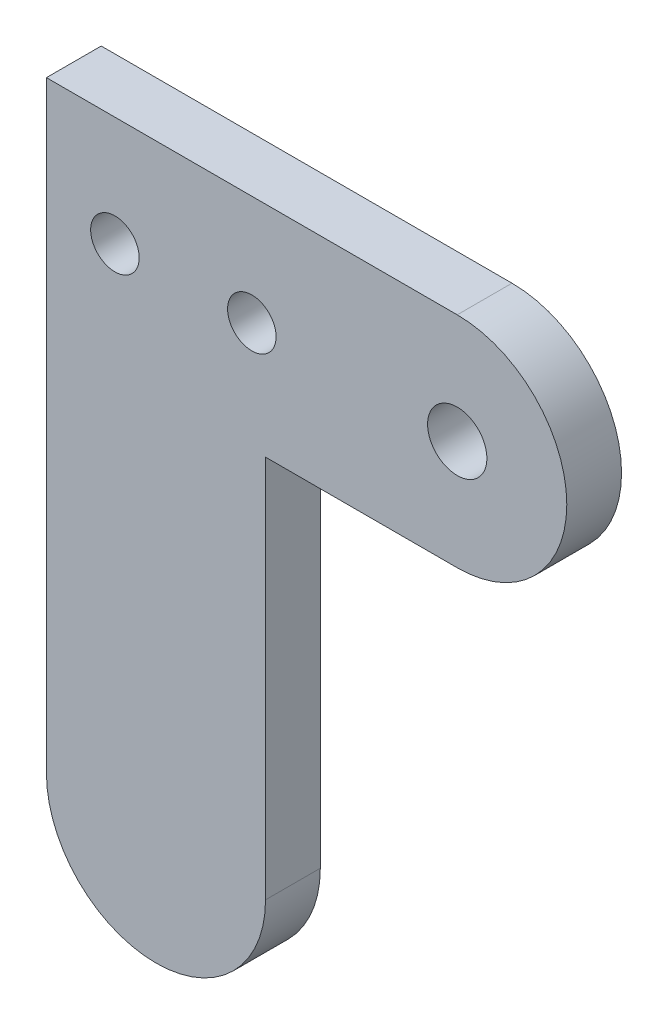
from build123d import *

# Parameters (mm, degrees)
BOSS_EXTRUDE1_DEPTH  = 5.08
M5_CLEARANCE_HOLE1_D = 5.5
M4_CLEARANCE_HOLE1_D = 4.5


with BuildPart() as part:
    # Sketch1 → Boss-Extrude1 (new body)
    with BuildSketch(Plane.XY):
        with BuildLine():
            Line((0, 10.16), (0, -10.16))
            Line((0, -10.16), (0, -45.72))
            ThreePointArc((0, -45.72), (10.16, -55.88), (20.32, -45.72))
            Line((20.32, -45.72), (20.32, -10.16))
            Line((20.32, -10.16), (38.1, -10.16))
            ThreePointArc((38.1, -10.16), (48.26, 0), (38.1, 10.16))
            Line((38.1, 10.16), (0, 10.16))
        make_face()
    extrude(amount=BOSS_EXTRUDE1_DEPTH)

    # M5 Clearance Hole1 (through all)
    with Locations(Plane.XY.offset(5.08)):
        with Locations((38.1, 0)):
            Hole(M5_CLEARANCE_HOLE1_D / 2)

    # M4 Clearance Hole1 (through all)
    with Locations(Plane.XY.offset(5.08)):
        with Locations((19.05, -0.016311357), (6.35, -0.016311357)):
            Hole(M4_CLEARANCE_HOLE1_D / 2)


solid = part.part
